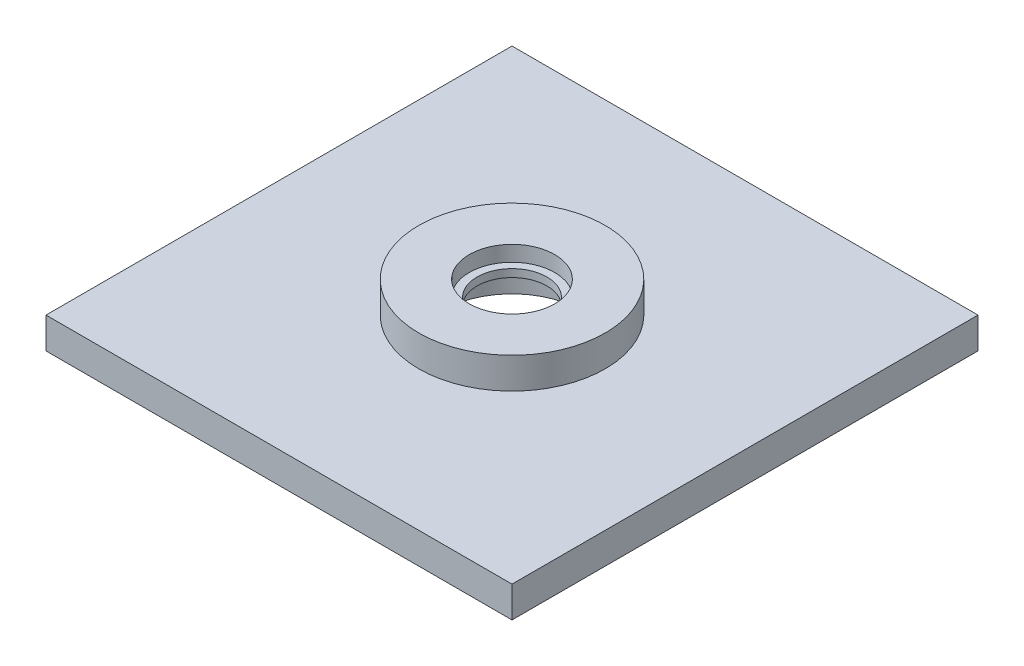
from build123d import *

# Parameters (mm, degrees)
SKETCH1_W           = 95.25
SKETCH1_H           = 95.25
SKETCH1_R           = 7.14375
BOSS_EXTRUDE1_DEPTH = 6.35
SKETCH3_R           = 19.05
SKETCH3_R_2         = 7.14375
BOSS_EXTRUDE2_DEPTH = 6.35
SKETCH2_R           = 14.2875
CUT_EXTRUDE1_DEPTH  = 7.9375
SKETCH4_R           = 8.73125
CUT_EXTRUDE2_DEPTH  = 3.175


with BuildPart() as part:
    # Sketch1 → Boss-Extrude1 (new body)
    with BuildSketch(Plane(origin=(0, 0, 0), x_dir=(1, 0, 0), z_dir=(0, 1, 0))):
        Rectangle(SKETCH1_W, SKETCH1_H)
        Circle(SKETCH1_R, mode=Mode.SUBTRACT)
    extrude(amount=BOSS_EXTRUDE1_DEPTH)

    # Sketch3 → Boss-Extrude2 (add)
    with BuildSketch(Plane(origin=(0, 6.35, 0), x_dir=(1, 0, 0), z_dir=(0, 1, 0))):
        Circle(SKETCH3_R)
        Circle(SKETCH3_R_2, mode=Mode.SUBTRACT)
    extrude(amount=BOSS_EXTRUDE2_DEPTH)

    # Sketch2 → Cut-Extrude1 (cut)
    with BuildSketch(Plane.XZ):
        Circle(SKETCH2_R)
    extrude(amount=-CUT_EXTRUDE1_DEPTH, mode=Mode.SUBTRACT)

    # Sketch4 → Cut-Extrude2 (cut)
    with BuildSketch(Plane(origin=(0, 12.7, 0), x_dir=(1, 0, 0), z_dir=(0, 1, 0))):
        Circle(SKETCH4_R)
    extrude(amount=-CUT_EXTRUDE2_DEPTH, mode=Mode.SUBTRACT)


solid = part.part
